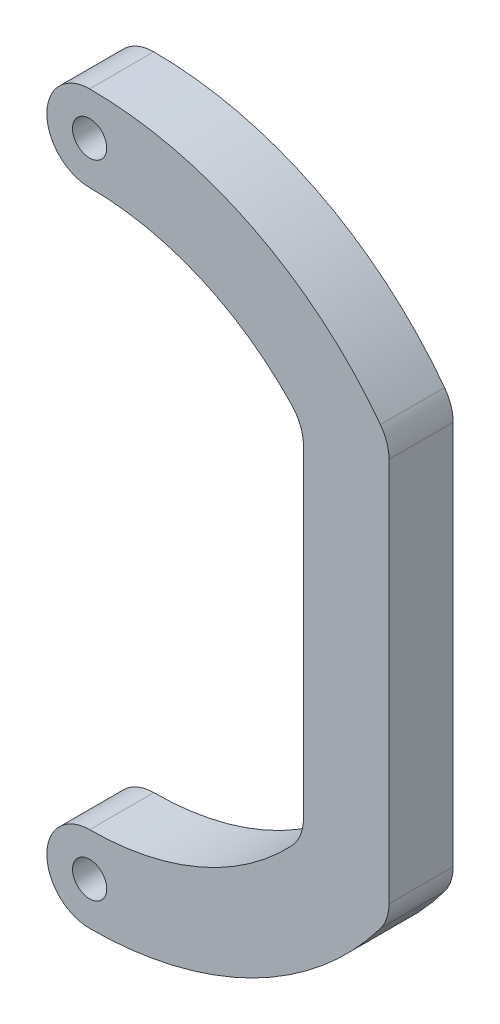
from build123d import *

# Parameters (mm, degrees)
SKIZZE1_R               = 4
LINEAR_AUSTRAGEN1_DEPTH = 15


with BuildPart() as part:
    # Skizze1 → Linear austragen1 (new body)
    with BuildSketch(Plane.XY):
        with BuildLine():
            Line((-25, -29.250827824), (-25, -104.749172176))
            ThreePointArc((-25, -104.749172176), (-25.706796227, -108.441916906), (-27.727272727, -111.612658027))
            ThreePointArc((-27.727272727, -111.612658027), (-49.259203312, -126.685939599), (-75, -132))
            ThreePointArc((-75, -132), (-85, -142), (-75, -152))
            ThreePointArc((-75, -152), (-36.986844383, -143.026311235), (-7, -118))
            ThreePointArc((-7, -118), (-5.513167019, -115.16227766), (-5, -112))
            Line((-5, -112), (-5, -22))
            ThreePointArc((-5, -22), (-5.513167019, -18.83772234), (-7, -16))
            ThreePointArc((-7, -16), (-36.986844383, 9.026311235), (-75, 18))
            ThreePointArc((-75, 18), (-85, 8), (-75, -2))
            ThreePointArc((-75, -2), (-49.259203312, -7.314060401), (-27.727272727, -22.387341973))
            ThreePointArc((-27.727272727, -22.387341973), (-25.706796227, -25.558083094), (-25, -29.250827824))
        make_face()
        with Locations((-75, -142)):
            Circle(SKIZZE1_R, mode=Mode.SUBTRACT)
        with Locations((-75, 8)):
            Circle(SKIZZE1_R, mode=Mode.SUBTRACT)
    extrude(amount=LINEAR_AUSTRAGEN1_DEPTH)


solid = part.part
